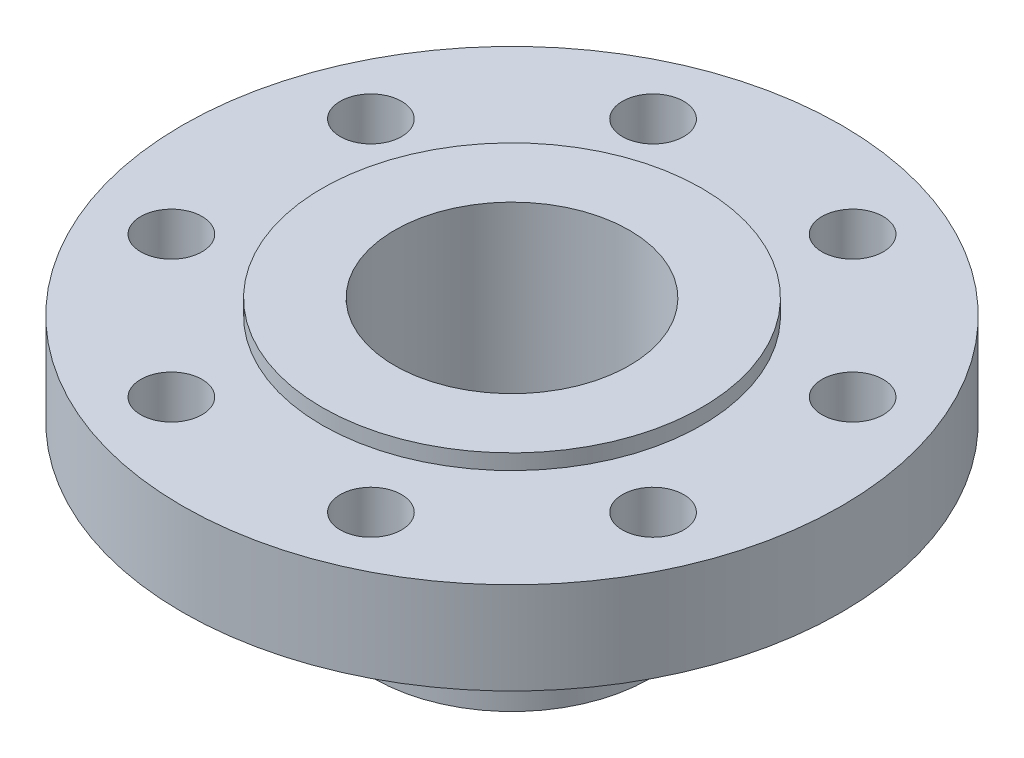
from build123d import *

# Parameters (mm, degrees)
ESBO_O2_R             = 12.7
CORTE_EXTRUS_O1_DEPTH = 102.6
PADR_OCIRCULAR1_COUNT = 8


with BuildPart() as part:
    # Esboço1 → Revolução1 (revolve)
    with BuildSketch(Plane.XY):
        Polygon((48.59, 0), (48.59, 107.95), (78.615, 107.95), (78.615, 101.6), (136.525, 101.6), (136.525, 63.5), (76.2, 63.5), (57.15, 12.29), (57.15, 0), align=None)
    revolve(axis=Axis((0, 0, 0), (0, 1, 0)))

    # Esboço2 → Corte-extrusão1 (cut, through all)
    with BuildSketch(Plane(origin=(0, 101.6, 0), x_dir=(1, 0, 0), z_dir=(0, 1, 0))):
        with Locations((41.310676524, 99.732795535)):
            Circle(ESBO_O2_R)
    corte_extrus_o1 = extrude(amount=-CORTE_EXTRUS_O1_DEPTH, mode=Mode.SUBTRACT)

    # PadrãoCircular1: Corte-extrusão1 ×8 about axis
    padr_ocircular1_axis = Axis((0, 0, 0), (0, 1, 0))
    for i in range(1, PADR_OCIRCULAR1_COUNT):
        add(corte_extrus_o1.rotate(padr_ocircular1_axis, i * 360 / PADR_OCIRCULAR1_COUNT), mode=Mode.SUBTRACT)


solid = part.part
